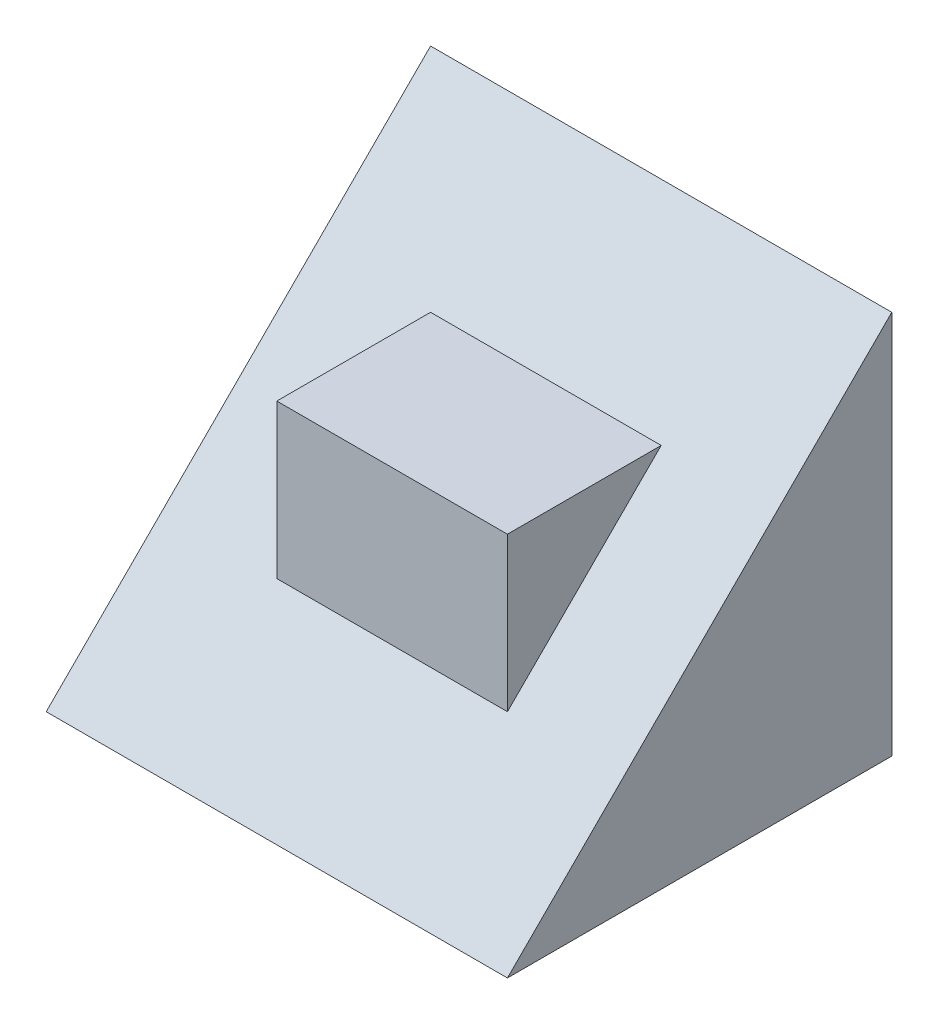
from build123d import *

# Parameters (mm, degrees)
BOSS_EXTRUDE1_DEPTH = 30
SKETCH2_W           = 35
SKETCH2_H           = 35
BOSS_EXTRUDE2_DEPTH = 15


with BuildPart() as part:
    # Sketch1 → Boss-Extrude1 (new body, symmetric)
    with BuildSketch(Plane(origin=(0, 0, 0), x_dir=(0, 0, -1), z_dir=(1, 0, 0))):
        Polygon((0, 0), (0, 50), (-50, 0), align=None)
    extrude(amount=BOSS_EXTRUDE1_DEPTH, both=True)

    # Sketch2 → Boss-Extrude2 (add, symmetric)
    with BuildSketch(Plane(origin=(0, 0, 0), x_dir=(0, 0, -1), z_dir=(1, 0, 0))):
        with Locations((-17.5, 17.5)):
            Rectangle(SKETCH2_W, SKETCH2_H)
    extrude(amount=BOSS_EXTRUDE2_DEPTH, both=True)


solid = part.part
